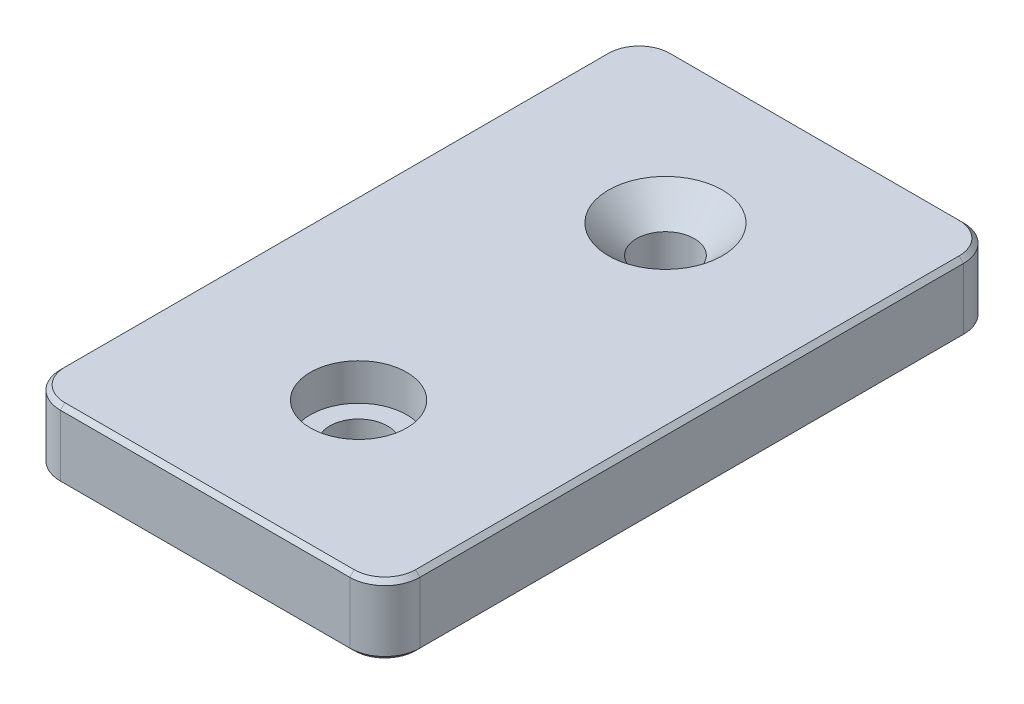
from build123d import *

# Parameters (mm, degrees)
SKETCH1_W           = 41
SKETCH1_H           = 70
SKETCH1_R           = 3.3
BOSS_EXTRUDE1_DEPTH = 8
SKETCH2_R           = 5.5
CUT_EXTRUDE1_DEPTH  = 4.2
CHAMFER2_SIZE       = 3.2
FILLET1_R           = 4
CHAMFER4_SIZE       = 0.5


with BuildPart() as part:
    # Sketch1 → Boss-Extrude1 (new body)
    with BuildSketch(Plane(origin=(0, 0, 0), x_dir=(1, 0, 0), z_dir=(0, 1, 0))):
        Rectangle(SKETCH1_W, SKETCH1_H)
        with Locations((0, 17.5)):
            Circle(SKETCH1_R, mode=Mode.SUBTRACT)
        with Locations((0, -17.5)):
            Circle(SKETCH1_R, mode=Mode.SUBTRACT)
    extrude(amount=BOSS_EXTRUDE1_DEPTH)

    # Sketch2 → Cut-Extrude1 (cut)
    with BuildSketch(Plane(origin=(0, 8, 0), x_dir=(1, 0, 0), z_dir=(0, 1, 0))):
        with Locations((0, -17.5)):
            Circle(SKETCH2_R)
    extrude(amount=-CUT_EXTRUDE1_DEPTH, mode=Mode.SUBTRACT)

    # Chamfer2
    chamfer2_edges = [part.edges().sort_by_distance(p)[0] for p in [
        (-3.3, 8, -17.5),
    ]]
    chamfer(chamfer2_edges, length=CHAMFER2_SIZE)

    # Fillet1
    fillet1_edges = [part.edges().sort_by_distance(p)[0] for p in [
        (20.5, 4, 35),
        (-20.5, 4, 35),
        (-20.5, 4, -35),
        (20.5, 4, -35),
    ]]
    fillet(fillet1_edges, radius=FILLET1_R)

    # Chamfer4
    chamfer4_edges = [part.edges().sort_by_distance(p)[0] for p in [
        (0, 0, 35),
        (0, 8, 35),
        (20.5, 0, 0),
        (-20.5, 0, 0),
        (0, 0, -35),
        (-19.328427125, 0, -33.828427125),
        (19.328427125, 0, -33.828427125),
        (19.328427125, 0, 33.828427125),
        (-19.328427125, 0, 33.828427125),
        (-20.5, 8, 0),
        (20.5, 8, 0),
        (0, 8, -35),
        (-19.328427125, 8, -33.828427125),
        (19.328427125, 8, -33.828427125),
        (19.328427125, 8, 33.828427125),
        (-19.328427125, 8, 33.828427125),
    ]]
    chamfer(chamfer4_edges, length=CHAMFER4_SIZE)


solid = part.part
